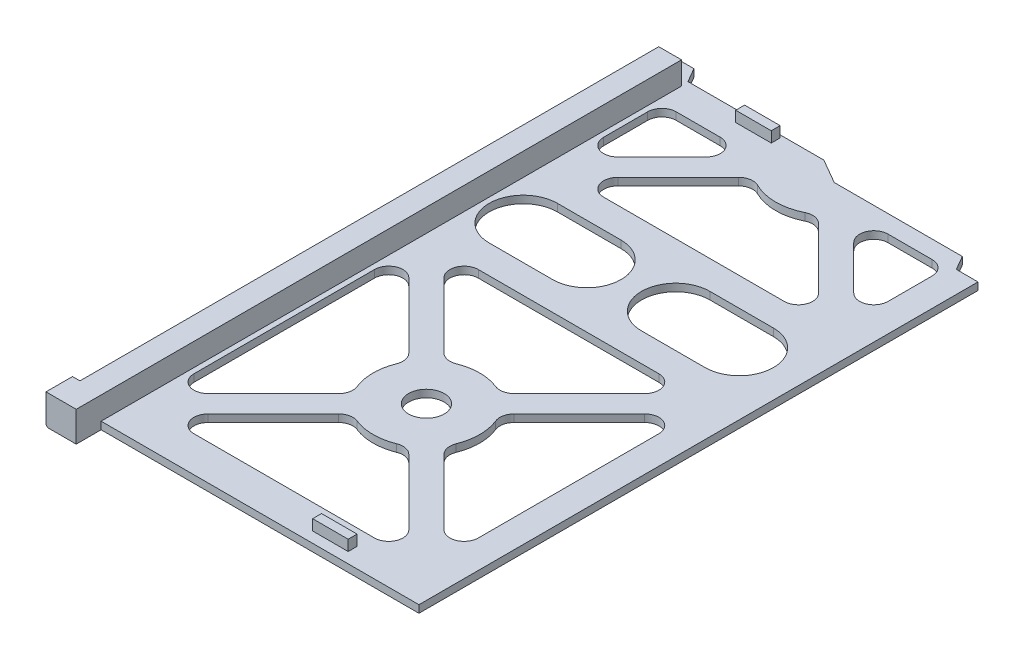
from build123d import *

# Parameters (mm, degrees)
SKETCH1_R           = 5
BOSS_EXTRUDE1_DEPTH = 2.1
SKETCH2_W           = 8.5
SKETCH2_H           = 170.25
BOSS_EXTRUDE2_DEPTH = 6.4
SKETCH3_W           = 162.8
SKETCH3_H           = 6.4
CUT_EXTRUDE1_DEPTH  = 2.1
SKETCH4_W           = 10
SKETCH4_H           = 2.5
BOSS_EXTRUDE3_DEPTH = 3
CHAMFER1_SIZE       = 0.5


with BuildPart() as part:
    # Sketch1 → Boss-Extrude1 (new body)
    with BuildSketch(Plane(origin=(0, 0, 0), x_dir=(1, 0, 0), z_dir=(0, 1, 0))):
        Polygon((-48.95, 0.55), (-48.95, -172.25), (-40.45, -172.25), (-40.45, -165.25), (48.95, -165.25), (48.95, -8), (42.85, -8), (40.540598923, -4), (4.514101615, -4), (-2.414101615, 0), (-40.640598923, 0), (-42.95, 4), (-48.95, 4), align=None)
        with BuildLine():
            Line((-13.76890063, -125.119153161), (-32.121572875, -143.471825407))
            ThreePointArc((-32.121572875, -143.471825407), (-36.480733729, -144.338916412), (-38.95, -140.643398282))
            Line((-38.95, -140.643398282), (-38.95, -89.856601718))
            ThreePointArc((-38.95, -89.856601718), (-36.480733729, -86.161083588), (-32.121572875, -87.028174593))
            Line((-32.121572875, -87.028174593), (-13.76890063, -105.380846839))
            ThreePointArc((-13.76890063, -105.380846839), (-12.679375, -107.403267629), (-12.882100859, -109.691532076))
            ThreePointArc((-12.882100859, -109.691532076), (-13.95, -115.25), (-12.882100859, -120.808467924))
            ThreePointArc((-12.882100859, -120.808467924), (-12.679375, -123.096732371), (-13.76890063, -125.119153161))
        make_face(mode=Mode.SUBTRACT)
        with BuildLine():
            ThreePointArc((-24.343398282, -155.25), (-28.038916412, -152.780733729), (-27.171825407, -148.421572875))
            Line((-27.171825407, -148.421572875), (-8.819153161, -130.06890063))
            ThreePointArc((-8.819153161, -130.06890063), (-6.796732371, -128.979375), (-4.508467924, -129.182100859))
            ThreePointArc((-4.508467924, -129.182100859), (1.05, -130.25), (6.608467924, -129.182100859))
            ThreePointArc((6.608467924, -129.182100859), (8.896732371, -128.979375), (10.919153161, -130.06890063))
            Line((10.919153161, -130.06890063), (29.271825407, -148.421572875))
            ThreePointArc((29.271825407, -148.421572875), (30.138916412, -152.780733729), (26.443398282, -155.25))
            Line((26.443398282, -155.25), (-24.343398282, -155.25))
        make_face(mode=Mode.SUBTRACT)
        with Locations((1.05, -115.25)):
            Circle(SKETCH1_R, mode=Mode.SUBTRACT)
        with BuildLine():
            Line((29.271825407, -82.078427125), (10.919153161, -100.43109937))
            ThreePointArc((10.919153161, -100.43109937), (8.896732371, -101.520625), (6.608467924, -101.317899141))
            ThreePointArc((6.608467924, -101.317899141), (1.05, -100.25), (-4.508467924, -101.317899141))
            ThreePointArc((-4.508467924, -101.317899141), (-6.796732371, -101.520625), (-8.819153161, -100.43109937))
            Line((-8.819153161, -100.43109937), (-27.171825407, -82.078427125))
            ThreePointArc((-27.171825407, -82.078427125), (-28.038916412, -77.719266271), (-24.343398282, -75.25))
            Line((-24.343398282, -75.25), (26.443398282, -75.25))
            ThreePointArc((26.443398282, -75.25), (30.138916412, -77.719266271), (29.271825407, -82.078427125))
        make_face(mode=Mode.SUBTRACT)
        with BuildLine():
            ThreePointArc((41.05, -140.643398282), (38.580733729, -144.338916412), (34.221572875, -143.471825407))
            Line((34.221572875, -143.471825407), (15.86890063, -125.119153161))
            ThreePointArc((15.86890063, -125.119153161), (14.779375, -123.096732371), (14.982100859, -120.808467924))
            ThreePointArc((14.982100859, -120.808467924), (16.05, -115.25), (14.982100859, -109.691532076))
            ThreePointArc((14.982100859, -109.691532076), (14.779375, -107.403267629), (15.86890063, -105.380846839))
            Line((15.86890063, -105.380846839), (34.221572875, -87.028174593))
            ThreePointArc((34.221572875, -87.028174593), (38.580733729, -86.161083588), (41.05, -89.856601718))
            Line((41.05, -89.856601718), (41.05, -140.643398282))
        make_face(mode=Mode.SUBTRACT)
        with BuildLine():
            ThreePointArc((-29.325, -67.25), (-38.95, -57.625), (-29.325, -48))
            Line((-29.325, -48), (-11.45, -48))
            ThreePointArc((-11.45, -48), (-1.825, -57.625), (-11.45, -67.25))
            Line((-11.45, -67.25), (-29.325, -67.25))
        make_face(mode=Mode.SUBTRACT)
        with BuildLine():
            ThreePointArc((-38.95, -13), (-37.778427125, -10.171572875), (-34.95, -9))
            Line((-34.95, -9), (-22.556601718, -9))
            ThreePointArc((-22.556601718, -9), (-18.861083588, -11.469266271), (-19.728174593, -15.828427125))
            Line((-19.728174593, -15.828427125), (-32.121572875, -28.221825407))
            ThreePointArc((-32.121572875, -28.221825407), (-36.480733729, -29.088916412), (-38.95, -25.393398282))
            Line((-38.95, -25.393398282), (-38.95, -13))
        make_face(mode=Mode.SUBTRACT)
        with BuildLine():
            ThreePointArc((13.55, -67.25), (3.925, -57.625), (13.55, -48))
            Line((13.55, -48), (31.425, -48))
            ThreePointArc((31.425, -48), (41.05, -57.625), (31.425, -67.25))
            Line((31.425, -67.25), (13.55, -67.25))
        make_face(mode=Mode.SUBTRACT)
        with BuildLine():
            ThreePointArc((-24.343398282, -40), (-28.038916412, -37.530733729), (-27.171825407, -33.171572875))
            Line((-27.171825407, -33.171572875), (-10.202325554, -16.202073022))
            ThreePointArc((-10.202325554, -16.202073022), (-8.02311566, -15.083537139), (-5.600446128, -15.445131695))
            ThreePointArc((-5.600446128, -15.445131695), (1.05, -17), (7.700446128, -15.445131695))
            ThreePointArc((7.700446128, -15.445131695), (10.12311566, -15.083537139), (12.302325554, -16.202073022))
            Line((12.302325554, -16.202073022), (29.271825407, -33.171572875))
            ThreePointArc((29.271825407, -33.171572875), (30.138916412, -37.530733729), (26.443398282, -40))
            Line((26.443398282, -40), (-24.343398282, -40))
        make_face(mode=Mode.SUBTRACT)
        with BuildLine():
            ThreePointArc((37.05, -9), (39.878427125, -10.171572875), (41.05, -13))
            Line((41.05, -13), (41.05, -25.393398282))
            ThreePointArc((41.05, -25.393398282), (38.580733729, -29.088916412), (34.221572875, -28.221825407))
            Line((34.221572875, -28.221825407), (21.828174593, -15.828427125))
            ThreePointArc((21.828174593, -15.828427125), (20.961083588, -11.469266271), (24.656601718, -9))
            Line((24.656601718, -9), (37.05, -9))
        make_face(mode=Mode.SUBTRACT)
    extrude(amount=BOSS_EXTRUDE1_DEPTH)

    # Sketch2 → Boss-Extrude2 (add)
    with BuildSketch(Plane(origin=(0, 2.1, 0), x_dir=(1, 0, 0), z_dir=(0, 1, 0))):
        with Locations((-44.7, -87.125)):
            Rectangle(SKETCH2_W, SKETCH2_H)
    extrude(amount=BOSS_EXTRUDE2_DEPTH)

    # Sketch3 → Cut-Extrude1 (cut)
    with BuildSketch(Plane.ZY.offset(48.95)):
        with Locations((83.4, 5.3)):
            Rectangle(SKETCH3_W, SKETCH3_H)
    extrude(amount=-CUT_EXTRUDE1_DEPTH, mode=Mode.SUBTRACT)

    # Sketch4 → Boss-Extrude3 (add)
    with BuildSketch(Plane(origin=(0, 2.1, 0), x_dir=(1, 0, 0), z_dir=(0, 1, 0))):
        with Locations((-18.95, -2)):
            Rectangle(SKETCH4_W, SKETCH4_H)
        with Locations((21.05, -161)):
            Rectangle(SKETCH4_W, SKETCH4_H)
    extrude(amount=BOSS_EXTRUDE3_DEPTH)

    # Chamfer1
    chamfer1_edges = [part.edges().sort_by_distance(p)[0] for p in [
        (-48.95, 0, 84.125),
    ]]
    chamfer(chamfer1_edges, length=CHAMFER1_SIZE)


solid = part.part
